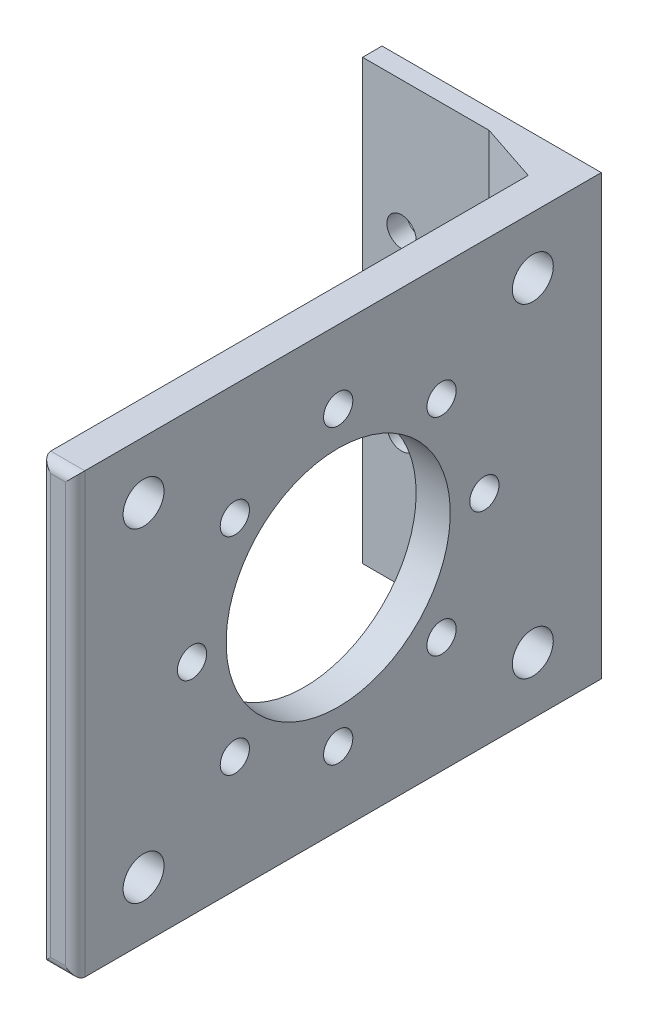
from build123d import *

# Parameters (mm, degrees)
SKETCH_1_W               = 22.5
SKETCH_1_H               = 45
EXTRUDE_1_DEPTH          = 2
SKETCH_2_W               = 3.5
SKETCH_2_H               = 45
EXTRUDE_2_DEPTH          = 52
CUT_EXTRUDE_2_REACH      = 24.5
SKETCH_3_R               = 2.1
SKETCH_3_R_2             = 11.5
SKETCH_3_R_3             = 1.5
CHAMFER_1_SIZE           = 6
CHAMFER_1_SIZE2          = 2
FILLET_1_R               = 1
SKETCH_4_R               = 1.5
CUT_EXTRUDE_3_DEPTH      = 5
SKETCH_5_R               = 2.24713436
CUT_EXTRUDE_4_DEPTH      = 15
CUT_EXTRUDE_4_DEPTH_BACK = 0.001


with BuildPart() as part:
    # 草图1 → 凸台-拉伸1 (new body)
    with BuildSketch(Plane.XY):
        with Locations((11.25, -22.5)):
            Rectangle(SKETCH_1_W, SKETCH_1_H)
    extrude(amount=EXTRUDE_1_DEPTH)

    # 草图2 → 凸台-拉伸2 (add)
    with BuildSketch(Plane.XY.offset(2)):
        with Locations((20.75, -22.5)):
            Rectangle(SKETCH_2_W, SKETCH_2_H)
    extrude(amount=EXTRUDE_2_DEPTH)

    # 草图3 → 切除-拉伸2 (cut, up to next)
    with BuildSketch(Plane(origin=(22.5, 0, 0), x_dir=(0, 0, -1), z_dir=(1, 0, 0)), mode=Mode.PRIVATE) as cut_extrude_2_sk1:
        with Locations((-46.97375327, -5.855205609)):
            Circle(SKETCH_3_R)
    cut_extrude_2_tool1 = extrude(cut_extrude_2_sk1.sketch, amount=-CUT_EXTRUDE_2_REACH, mode=Mode.PRIVATE) & part.part
    add(cut_extrude_2_tool1.solids().sort_by_distance((22.5, -5.855206, 46.973753))[0], mode=Mode.SUBTRACT)
    # 草图3 → 切除-拉伸2 (cut, up to next)
    with BuildSketch(Plane(origin=(22.5, 0, 0), x_dir=(0, 0, -1), z_dir=(1, 0, 0)), mode=Mode.PRIVATE) as cut_extrude_2_sk2:
        with Locations((-7.02624673, -39.144794391)):
            Circle(SKETCH_3_R)
    cut_extrude_2_tool2 = extrude(cut_extrude_2_sk2.sketch, amount=-CUT_EXTRUDE_2_REACH, mode=Mode.PRIVATE) & part.part
    add(cut_extrude_2_tool2.solids().sort_by_distance((22.5, -39.144794, 7.026247))[0], mode=Mode.SUBTRACT)
    # 草图3 → 切除-拉伸2 (cut, up to next)
    with BuildSketch(Plane(origin=(22.5, 0, 0), x_dir=(0, 0, -1), z_dir=(1, 0, 0)), mode=Mode.PRIVATE) as cut_extrude_2_sk3:
        with Locations((-27, -22.5)):
            Circle(SKETCH_3_R_2)
    cut_extrude_2_tool3 = extrude(cut_extrude_2_sk3.sketch, amount=-CUT_EXTRUDE_2_REACH, mode=Mode.PRIVATE) & part.part
    add(cut_extrude_2_tool3.solids().sort_by_distance((22.5, -22.5, 27))[0], mode=Mode.SUBTRACT)
    # 草图3 → 切除-拉伸2 (cut, up to next)
    with BuildSketch(Plane(origin=(22.5, 0, 0), x_dir=(0, 0, -1), z_dir=(1, 0, 0)), mode=Mode.PRIVATE) as cut_extrude_2_sk4:
        with Locations((-46.97375327, -39.144794391)):
            Circle(SKETCH_3_R)
    cut_extrude_2_tool4 = extrude(cut_extrude_2_sk4.sketch, amount=-CUT_EXTRUDE_2_REACH, mode=Mode.PRIVATE) & part.part
    add(cut_extrude_2_tool4.solids().sort_by_distance((22.5, -39.144794, 46.973753))[0], mode=Mode.SUBTRACT)
    # 草图3 → 切除-拉伸2 (cut, up to next)
    with BuildSketch(Plane(origin=(22.5, 0, 0), x_dir=(0, 0, -1), z_dir=(1, 0, 0)), mode=Mode.PRIVATE) as cut_extrude_2_sk5:
        with Locations((-7.02624673, -5.855205609)):
            Circle(SKETCH_3_R)
    cut_extrude_2_tool5 = extrude(cut_extrude_2_sk5.sketch, amount=-CUT_EXTRUDE_2_REACH, mode=Mode.PRIVATE) & part.part
    add(cut_extrude_2_tool5.solids().sort_by_distance((22.5, -5.855206, 7.026247))[0], mode=Mode.SUBTRACT)
    # 草图3 → 切除-拉伸2 (cut, up to next)
    with BuildSketch(Plane(origin=(22.5, 0, 0), x_dir=(0, 0, -1), z_dir=(1, 0, 0)), mode=Mode.PRIVATE) as cut_extrude_2_sk6:
        with Locations((-42, -22.5)):
            Circle(SKETCH_3_R_3)
    cut_extrude_2_tool6 = extrude(cut_extrude_2_sk6.sketch, amount=-CUT_EXTRUDE_2_REACH, mode=Mode.PRIVATE) & part.part
    add(cut_extrude_2_tool6.solids().sort_by_distance((22.5, -22.5, 42))[0], mode=Mode.SUBTRACT)
    # 草图3 → 切除-拉伸2 (cut, up to next)
    with BuildSketch(Plane(origin=(22.5, 0, 0), x_dir=(0, 0, -1), z_dir=(1, 0, 0)), mode=Mode.PRIVATE) as cut_extrude_2_sk7:
        with Locations((-37.606601718, -11.893398282)):
            Circle(SKETCH_3_R_3)
    cut_extrude_2_tool7 = extrude(cut_extrude_2_sk7.sketch, amount=-CUT_EXTRUDE_2_REACH, mode=Mode.PRIVATE) & part.part
    add(cut_extrude_2_tool7.solids().sort_by_distance((22.5, -11.893398, 37.606602))[0], mode=Mode.SUBTRACT)
    # 草图3 → 切除-拉伸2 (cut, up to next)
    with BuildSketch(Plane(origin=(22.5, 0, 0), x_dir=(0, 0, -1), z_dir=(1, 0, 0)), mode=Mode.PRIVATE) as cut_extrude_2_sk8:
        with Locations((-27, -7.5)):
            Circle(SKETCH_3_R_3)
    cut_extrude_2_tool8 = extrude(cut_extrude_2_sk8.sketch, amount=-CUT_EXTRUDE_2_REACH, mode=Mode.PRIVATE) & part.part
    add(cut_extrude_2_tool8.solids().sort_by_distance((22.5, -7.5, 27))[0], mode=Mode.SUBTRACT)
    # 草图3 → 切除-拉伸2 (cut, up to next)
    with BuildSketch(Plane(origin=(22.5, 0, 0), x_dir=(0, 0, -1), z_dir=(1, 0, 0)), mode=Mode.PRIVATE) as cut_extrude_2_sk9:
        with Locations((-16.393398282, -11.893398282)):
            Circle(SKETCH_3_R_3)
    cut_extrude_2_tool9 = extrude(cut_extrude_2_sk9.sketch, amount=-CUT_EXTRUDE_2_REACH, mode=Mode.PRIVATE) & part.part
    add(cut_extrude_2_tool9.solids().sort_by_distance((22.5, -11.893398, 16.393398))[0], mode=Mode.SUBTRACT)
    # 草图3 → 切除-拉伸2 (cut, up to next)
    with BuildSketch(Plane(origin=(22.5, 0, 0), x_dir=(0, 0, -1), z_dir=(1, 0, 0)), mode=Mode.PRIVATE) as cut_extrude_2_sk10:
        with Locations((-12, -22.5)):
            Circle(SKETCH_3_R_3)
    cut_extrude_2_tool10 = extrude(cut_extrude_2_sk10.sketch, amount=-CUT_EXTRUDE_2_REACH, mode=Mode.PRIVATE) & part.part
    add(cut_extrude_2_tool10.solids().sort_by_distance((22.5, -22.5, 12))[0], mode=Mode.SUBTRACT)
    # 草图3 → 切除-拉伸2 (cut, up to next)
    with BuildSketch(Plane(origin=(22.5, 0, 0), x_dir=(0, 0, -1), z_dir=(1, 0, 0)), mode=Mode.PRIVATE) as cut_extrude_2_sk11:
        with Locations((-16.393398282, -33.106601718)):
            Circle(SKETCH_3_R_3)
    cut_extrude_2_tool11 = extrude(cut_extrude_2_sk11.sketch, amount=-CUT_EXTRUDE_2_REACH, mode=Mode.PRIVATE) & part.part
    add(cut_extrude_2_tool11.solids().sort_by_distance((22.5, -33.106602, 16.393398))[0], mode=Mode.SUBTRACT)
    # 草图3 → 切除-拉伸2 (cut, up to next)
    with BuildSketch(Plane(origin=(22.5, 0, 0), x_dir=(0, 0, -1), z_dir=(1, 0, 0)), mode=Mode.PRIVATE) as cut_extrude_2_sk12:
        with Locations((-27, -37.5)):
            Circle(SKETCH_3_R_3)
    cut_extrude_2_tool12 = extrude(cut_extrude_2_sk12.sketch, amount=-CUT_EXTRUDE_2_REACH, mode=Mode.PRIVATE) & part.part
    add(cut_extrude_2_tool12.solids().sort_by_distance((22.5, -37.5, 27))[0], mode=Mode.SUBTRACT)
    # 草图3 → 切除-拉伸2 (cut, up to next)
    with BuildSketch(Plane(origin=(22.5, 0, 0), x_dir=(0, 0, -1), z_dir=(1, 0, 0)), mode=Mode.PRIVATE) as cut_extrude_2_sk13:
        with Locations((-37.606601718, -33.106601718)):
            Circle(SKETCH_3_R_3)
    cut_extrude_2_tool13 = extrude(cut_extrude_2_sk13.sketch, amount=-CUT_EXTRUDE_2_REACH, mode=Mode.PRIVATE) & part.part
    add(cut_extrude_2_tool13.solids().sort_by_distance((22.5, -33.106602, 37.606602))[0], mode=Mode.SUBTRACT)

    # 倒角1
    chamfer_1_edges = [part.edges().sort_by_distance(p)[0] for p in [
        (19, -22.5, 2),
    ]]
    chamfer_1_side = [part.faces().sort_by_distance(p)[0] for p in [
        (9.5, -22.5, 2),
    ]]
    chamfer(chamfer_1_edges, length=CHAMFER_1_SIZE, length2=CHAMFER_1_SIZE2, reference=chamfer_1_side[0])

    # 圆角1
    fillet_1_edges = [part.edges().sort_by_distance(p)[0] for p in [
        (20.75, 0, 54),
        (19, -22.5, 54),
        (20.75, -45, 54),
        (22.5, -22.5, 54),
    ]]
    fillet(fillet_1_edges, radius=FILLET_1_R)

    # 草图4 → 切除-拉伸3 (cut, symmetric)
    with BuildSketch(Plane.XY.offset(2)):
        with Locations((4, -31.5)):
            Circle(SKETCH_4_R)
        with Locations((4, -13.5)):
            Circle(SKETCH_4_R)
        with Locations((16, -13.5)):
            Circle(SKETCH_4_R)
        with Locations((16, -31.5)):
            Circle(SKETCH_4_R)
    extrude(amount=CUT_EXTRUDE_3_DEPTH, both=True, mode=Mode.SUBTRACT)

    # 草图5 → 切除-拉伸4 (cut, two sides)
    with BuildSketch(Plane.XY.offset(2)) as cut_extrude_4_sk:
        with Locations((16, -13.5)):
            Circle(SKETCH_5_R)
        with Locations((16, -31.5)):
            Circle(SKETCH_5_R)
    extrude(amount=CUT_EXTRUDE_4_DEPTH, mode=Mode.SUBTRACT)
    extrude(cut_extrude_4_sk.sketch, amount=-CUT_EXTRUDE_4_DEPTH_BACK, mode=Mode.SUBTRACT)


solid = part.part
